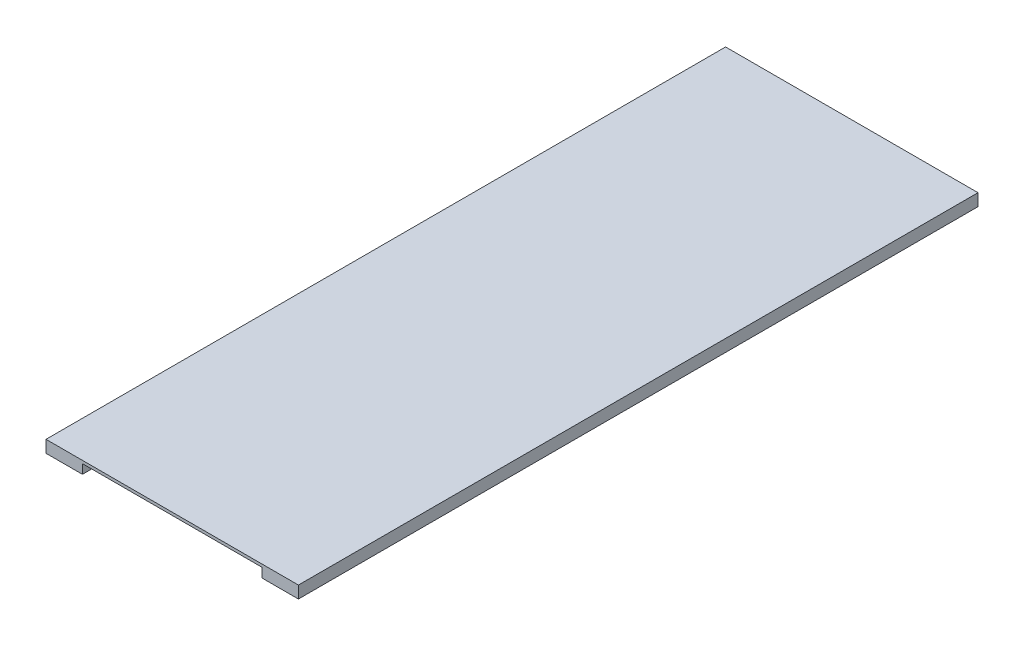
from build123d import *

# Parameters (mm, degrees)
BOSS_EXTRUDE1_DEPTH = 280


with BuildPart() as part:
    # Sketch1 → Boss-Extrude1 (new body)
    with BuildSketch(Plane.XY):
        Polygon((-15, -3.828082647), (-15, 1.171917353), (89, 1.171917353), (89, -3.828082647), (74, -3.828082647), (74, 0), (0, 0), (0, -3.828082647), align=None)
    extrude(amount=BOSS_EXTRUDE1_DEPTH)


solid = part.part
